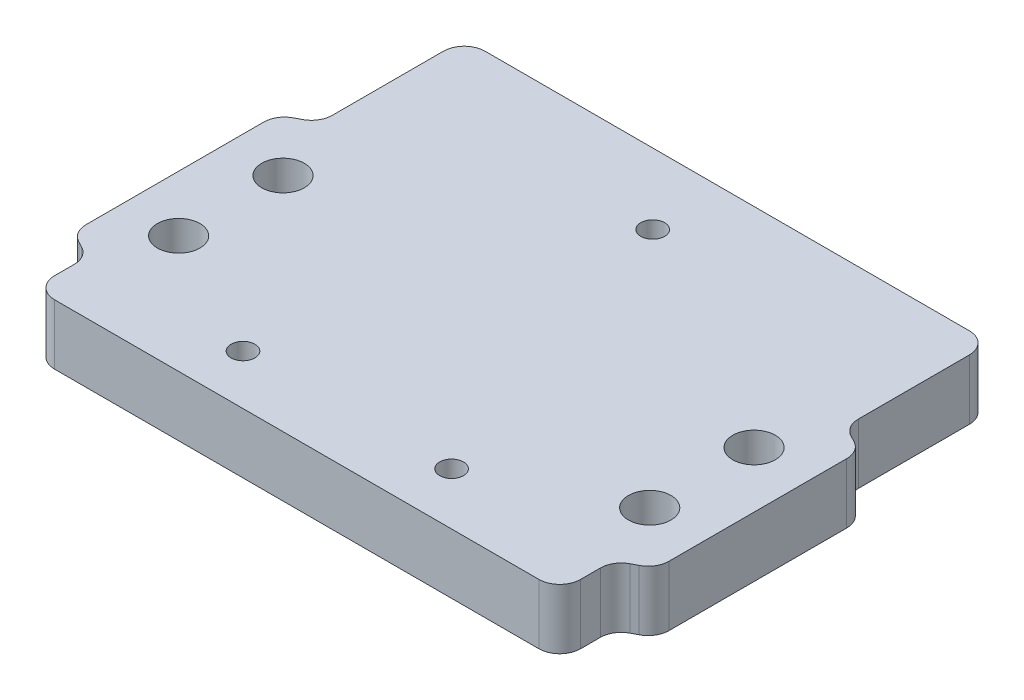
from build123d import *

# Parameters (mm, degrees)
SKETCH1_W                                         = 70.945719932
SKETCH1_H                                         = 63.5
BOSS_EXTRUDE1_DEPTH                               = 7.3152
F_6_0_204_DIAMETER_HOLE1_D                        = 5.1816
FILLET1_R                                         = 2.54
CUT_EXTRUDE1_START                                = -8.3152
CUT_EXTRUDE1_DEPTH                                = 9.3152
FILLET2_R                                         = 2.54
MIRROR5_START                                     = -8.3152
MIRROR5_COPY_1_DEPTH                              = 9.3152
FILLET2_OF_MIRROR5_R                              = 2.54
CSK_FOR_M2_5_FLAT_HEAD_MACHINE_SCREW1_D           = 2.9
CSK_FOR_M2_5_FLAT_HEAD_MACHINE_SCREW1_CSINK_D     = 5.5
CSK_FOR_M2_5_FLAT_HEAD_MACHINE_SCREW1_CSINK_ANGLE = 90
FILLET3_R                                         = 2.54
SKETCH8_W                                         = 76.945893843
SKETCH8_H                                         = 15.876044122
CUT_EXTRUDE2_DEPTH                                = 8.3152
FILLET4_R                                         = 2.54


with BuildPart() as part:
    # Sketch1 → Boss-Extrude1 (new body)
    with BuildSketch(Plane(origin=(0, 0, 0), x_dir=(1, 0, 0), z_dir=(0, 1, 0))):
        Rectangle(SKETCH1_W, SKETCH1_H)
    extrude(amount=BOSS_EXTRUDE1_DEPTH)

    # 6 _0.204_ Diameter Hole1 (through all)
    with Locations(Plane(origin=(-28.662459966, 7.3152, 6.35), x_dir=(0, 0, 1), z_dir=(0, 1, 0))):
        with Locations((0, 0), (-12.7, 0)):
            f_6_0_204_diameter_hole1 = Hole(F_6_0_204_DIAMETER_HOLE1_D / 2)

    # Mirror2: 6 _0.204_ Diameter Hole1 across plane
    add(f_6_0_204_diameter_hole1.mirror(Plane(origin=(0, 0, 0), x_dir=(0, 0, 1), z_dir=(1, 0, 0))), mode=Mode.SUBTRACT)

    # Fillet1
    fillet1_edges = [part.edges().sort_by_distance(p)[0] for p in [
        (-35.472859966, 3.6576, -31.75),
        (35.472859966, 3.6576, -31.75),
        (35.472859966, 3.6576, 31.75),
        (-35.472859966, 3.6576, 31.75),
    ]]
    fillet(fillet1_edges, radius=FILLET1_R)

    # Sketch4 → Cut-Extrude1 (cut)
    with BuildSketch(Plane(origin=(0, 7.3152, 0), x_dir=(1, 0, 0), z_dir=(0, 1, 0)).offset(CUT_EXTRUDE1_START)):
        Polygon((-35.472859966, 12.353878123), (-32.008017694, 14.155210535), (-32.008017694, 31.75), (-35.472859966, 31.75), align=None)
    cut_extrude1 = extrude(amount=CUT_EXTRUDE1_DEPTH, mode=Mode.SUBTRACT)

    # Mirror4: Cut-Extrude1 across plane
    add(cut_extrude1.mirror(Plane(origin=(0, 0, 0), x_dir=(0, 0, 1), z_dir=(1, 0, 0))), mode=Mode.SUBTRACT)

    # Fillet2
    fillet2_edges = [part.edges().sort_by_distance(p)[0] for p in [
        (-35.472859966, 3.6576, -12.353878123),
        (-32.008017694, 3.6576, -14.155210535),
        (35.472859966, 3.6576, -12.353878123),
        (32.008017694, 3.6576, -14.155210535),
    ]]
    fillet(fillet2_edges, radius=FILLET2_R)

    # Mirror5: Cut-Extrude1 across plane
    add(cut_extrude1.mirror(Plane.XY), mode=Mode.SUBTRACT)

    # Mirror5 copy 1 sketch → Mirror5 copy 1 (cut)
    with BuildSketch(Plane(origin=(0, 7.3152, 0), x_dir=(-1, 0, 0), z_dir=(0, 1, 0)).offset(MIRROR5_START)):
        Polygon((-35.472859966, 12.353878123), (-32.008017694, 14.155210535), (-32.008017694, 31.75), (-35.472859966, 31.75), align=None)
    extrude(amount=MIRROR5_COPY_1_DEPTH, mode=Mode.SUBTRACT)

    # Fillet2 of Mirror5
    fillet2_of_mirror5_edges = [part.edges().sort_by_distance(p)[0] for p in [
        (-35.472859966, 3.6576, 12.353878123),
        (-32.008017694, 3.6576, 14.155210535),
        (35.472859966, 3.6576, 12.353878123),
        (32.008017694, 3.6576, 14.155210535),
    ]]
    fillet(fillet2_of_mirror5_edges, radius=FILLET2_OF_MIRROR5_R)

    # CSK for M2.5 Flat Head Machine Screw1 (through all)
    with Locations(Plane(origin=(0, 0, 0), x_dir=(-1, 0, 0), z_dir=(0, -1, 0))):
        with Locations((-12.498696024, -14.301128674), (12.599674998, -14.58708679), (0.478857024, 23.153452046)):
            CounterSinkHole(CSK_FOR_M2_5_FLAT_HEAD_MACHINE_SCREW1_D / 2, CSK_FOR_M2_5_FLAT_HEAD_MACHINE_SCREW1_CSINK_D / 2, counter_sink_angle=CSK_FOR_M2_5_FLAT_HEAD_MACHINE_SCREW1_CSINK_ANGLE)

    # Fillet3
    fillet3_edges = [part.edges().sort_by_distance(p)[0] for p in [
        (-32.008017694, 3.6576, 31.75),
        (32.008017694, 3.6576, 31.75),
        (-32.008017694, 3.6576, -31.75),
        (32.008017694, 3.6576, -31.75),
    ]]
    fillet(fillet3_edges, radius=FILLET3_R)

    # Sketch8 → Cut-Extrude2 (cut, through all)
    with BuildSketch(Plane(origin=(0, 7.3152, 0), x_dir=(1, 0, 0), z_dir=(0, 1, 0))):
        with Locations((2.091748304, -28.581066923)):
            Rectangle(SKETCH8_W, SKETCH8_H)
    extrude(amount=-CUT_EXTRUDE2_DEPTH, mode=Mode.SUBTRACT)

    # Fillet4
    fillet4_edges = [part.edges().sort_by_distance(p)[0] for p in [
        (32.008017694, 3.6576, 20.643044862),
        (-32.008017694, 3.6576, 20.643044862),
    ]]
    fillet(fillet4_edges, radius=FILLET4_R)


solid = part.part
